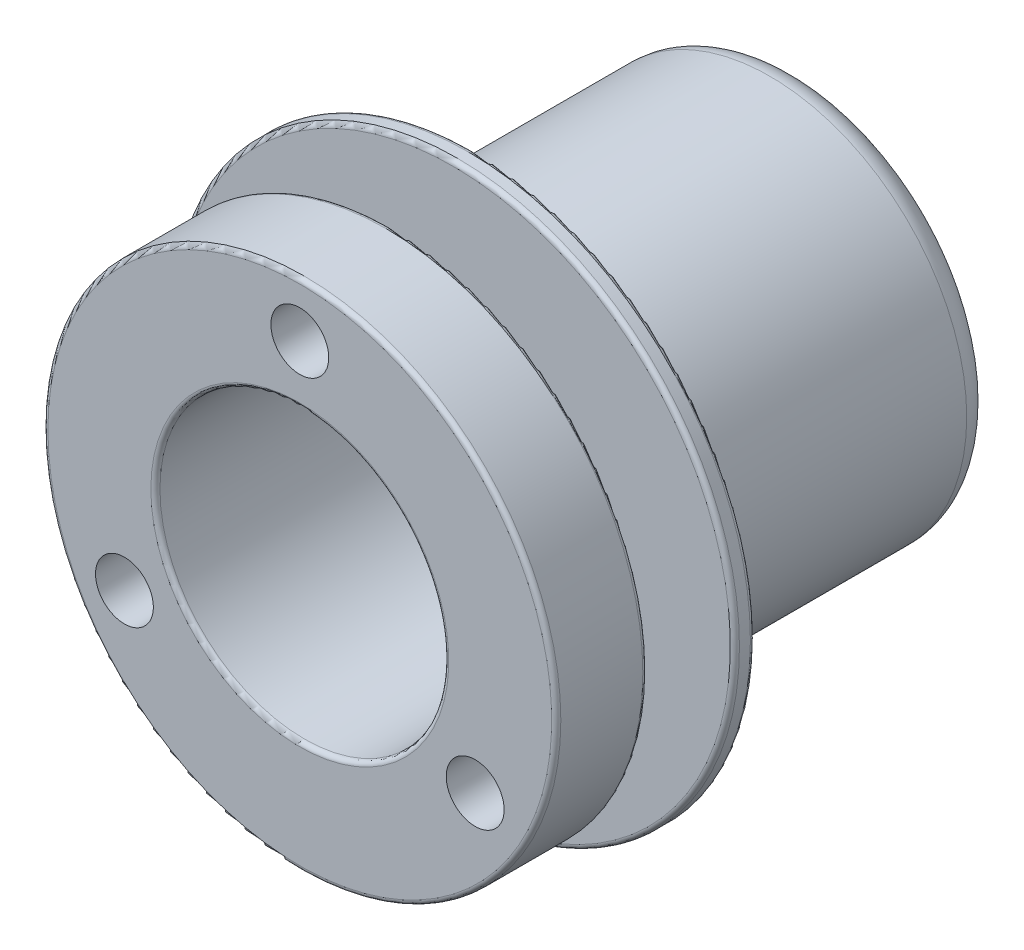
from build123d import *

# Parameters (mm, degrees)
FILLET1_R          = 0.5
CUT_EXTRUDE1_REACH = 56.6
SKETCH2_R          = 3.175


with BuildPart() as part:
    # Sketch1 → Revolve1 (revolve)
    with BuildSketch(Plane(origin=(0, 0, 0), x_dir=(0, 0, -1), z_dir=(1, 0, 0))):
        with BuildLine():
            Line((0, 15.85), (0, 28.15))
            Line((0, 28.15), (10, 28.15))
            Line((10, 28.15), (10, 17.35))
            Line((10, 17.35), (16.804567413, 17.35))
            Line((16.804567413, 17.35), (16.804567413, 30.95))
            Line((16.804567413, 30.95), (19.004567413, 30.95))
            Line((19.004567413, 30.95), (19.004567413, 21.6))
            Line((19.004567413, 21.6), (51.6, 21.6))
            ThreePointArc((51.6, 21.6), (53.721320344, 20.721320344), (54.6, 18.6))
            Line((54.6, 18.6), (54.6, 15.85))
            Line((54.6, 15.85), (0, 15.85))
        make_face()
    revolve(axis=Axis((0, 0, 9.862432658), (0, 0, -1)))

    # Fillet1
    fillet1_edges = [part.edges().sort_by_distance(p)[0] for p in [
        (0, -28.15, -10),
        (0, -28.15, 0),
        (0, -15.85, 0),
        (0, -30.95, -19.004567413),
        (0, -30.95, -16.804567413),
    ]]
    fillet(fillet1_edges, radius=FILLET1_R)

    # Sketch2 → Cut-Extrude1 (cut, up to next)
    with BuildSketch(Plane.XY, mode=Mode.PRIVATE) as cut_extrude1_sk1:
        with Locations((0, 22.225)):
            Circle(SKETCH2_R)
    cut_extrude1_tool1 = extrude(cut_extrude1_sk1.sketch, amount=-CUT_EXTRUDE1_REACH, mode=Mode.PRIVATE) & part.part
    add(cut_extrude1_tool1.solids().sort_by_distance((0, 22.225, 0))[0], mode=Mode.SUBTRACT)
    # Sketch2 → Cut-Extrude1 (cut, up to next)
    with BuildSketch(Plane.XY, mode=Mode.PRIVATE) as cut_extrude1_sk2:
        with Locations((19.247414599, -11.1125)):
            Circle(SKETCH2_R)
    cut_extrude1_tool2 = extrude(cut_extrude1_sk2.sketch, amount=-CUT_EXTRUDE1_REACH, mode=Mode.PRIVATE) & part.part
    add(cut_extrude1_tool2.solids().sort_by_distance((19.247415, -11.1125, 0))[0], mode=Mode.SUBTRACT)
    # Sketch2 → Cut-Extrude1 (cut, up to next)
    with BuildSketch(Plane.XY, mode=Mode.PRIVATE) as cut_extrude1_sk3:
        with Locations((-19.247414599, -11.1125)):
            Circle(SKETCH2_R)
    cut_extrude1_tool3 = extrude(cut_extrude1_sk3.sketch, amount=-CUT_EXTRUDE1_REACH, mode=Mode.PRIVATE) & part.part
    add(cut_extrude1_tool3.solids().sort_by_distance((-19.247415, -11.1125, 0))[0], mode=Mode.SUBTRACT)


solid = part.part
